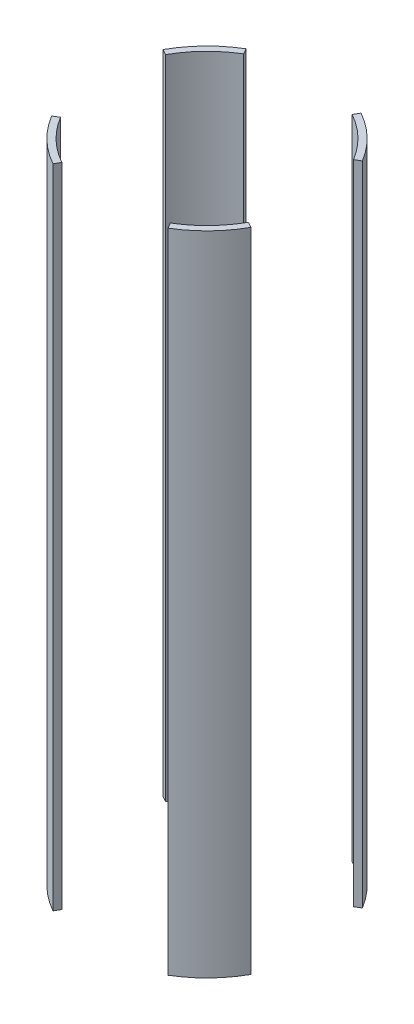
from build123d import *

# Parameters (mm, degrees)
SKETCH2_R               = 88.9
SKETCH2_R_2             = 83.82
BOSS_EXTRUDE1_DEPTH     = 254
CUT_EXTRUDE1_DEPTH      = 255
CUT_EXTRUDE1_DEPTH_BACK = 255


with BuildPart() as part:
    # Sketch2 → Boss-Extrude1 (new body, symmetric)
    with BuildSketch(Plane(origin=(0, 0, 0), x_dir=(1, 0, 0), z_dir=(0, 1, 0))):
        Circle(SKETCH2_R)
        Circle(SKETCH2_R_2, mode=Mode.SUBTRACT)
    extrude(amount=BOSS_EXTRUDE1_DEPTH, both=True)

    # Sketch3 → Cut-Extrude1 (cut, two sides)
    with BuildSketch(Plane(origin=(0, 0, 0), x_dir=(1, 0, 0), z_dir=(0, 1, 0))) as cut_extrude1_sk:
        Polygon((169.661755759, -94.300371224), (0, 0), (169.661755759, 101.677593364), align=None)
        Polygon((0, 0), (53.900027233, 96.974944394), (-58.116685864, 96.974944394), align=None)
        Polygon((-123.741299607, 68.777140945), (-123.741299607, -74.157652604), (0, 0), align=None)
        Polygon((-65.840936026, -118.45858783), (0, 0), (70.991745134, -118.45858783), align=None)
    extrude(amount=CUT_EXTRUDE1_DEPTH, mode=Mode.SUBTRACT)
    extrude(cut_extrude1_sk.sketch, amount=-CUT_EXTRUDE1_DEPTH_BACK, mode=Mode.SUBTRACT)


solid = part.part
